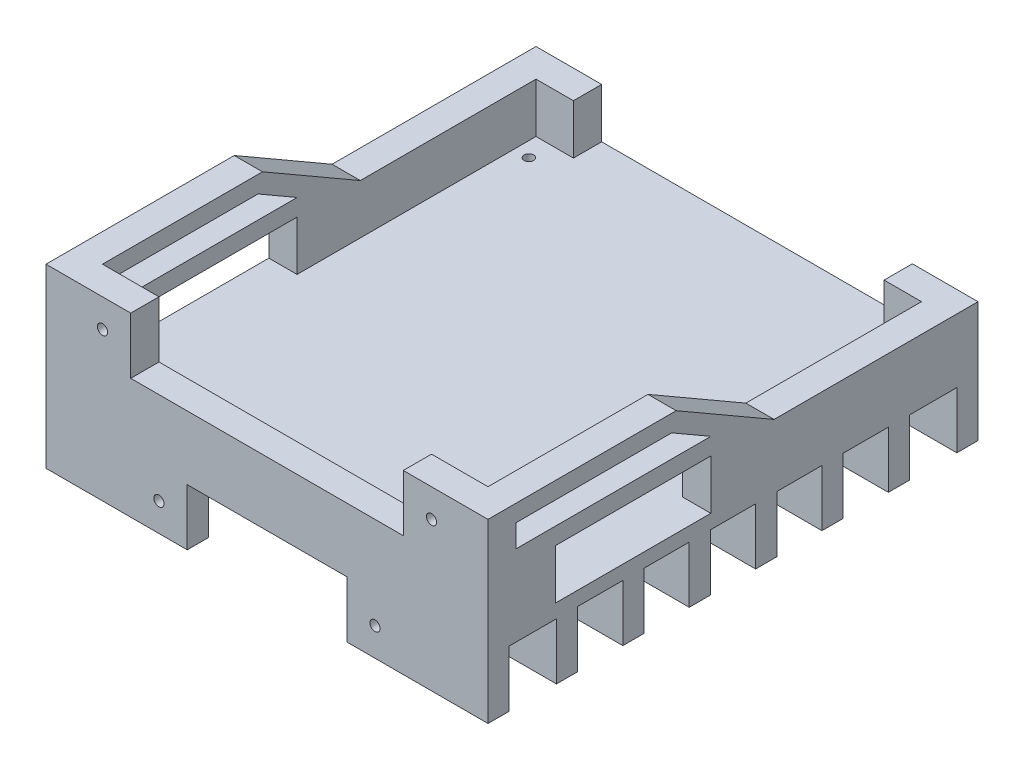
from build123d import *

# Parameters (mm, degrees)
SKETCH1_W            = 156.5
SKETCH1_H            = 173.5
BOSS_EXTRUDE1_DEPTH  = 5
BOSS_EXTRUDE2_DEPTH  = 17.6
M3_CLEARANCE_HOLE1_D = 3.4
SKETCH6_W            = 50
SKETCH6_H            = 7.5
BOSS_EXTRUDE3_DEPTH  = 20
BOSS_EXTRUDE5_DEPTH  = 10
SKETCH8_W            = 20
SKETCH8_H            = 20
SKETCH8_R            = 1.8
BOSS_EXTRUDE6_DEPTH  = 10
SKETCH9_R            = 1.8
CUT_EXTRUDE1_DEPTH   = 8.5


with BuildPart() as part:
    # Sketch1 → Boss-Extrude1 (new body)
    with BuildSketch(Plane(origin=(0, 0, 0), x_dir=(1, 0, 0), z_dir=(0, 1, 0))):
        Rectangle(SKETCH1_W, SKETCH1_H)
    extrude(amount=-BOSS_EXTRUDE1_DEPTH)

    # Sketch1_2 → Boss-Extrude2 (add)
    with BuildSketch(Plane(origin=(0, 0, 0), x_dir=(1, 0, 0), z_dir=(0, 1, 0))):
        Polygon((-78.25, -7.85), (-68.25, -7.85), (-68.25, 76.75), (-55, 76.75), (-55, 86.75), (-78.25, 86.75), align=None)
        Polygon((68.25, 76.75), (68.25, -7.85), (78.25, -7.85), (78.25, 86.75), (55, 86.75), (55, 76.75), align=None)
        Polygon((68.25, -76.75), (-68.25, -76.75), (-68.25, -62.85), (-78.25, -62.85), (-78.25, -86.75), (78.25, -86.75), (78.25, -62.85), (68.25, -62.85), align=None)
    extrude(amount=BOSS_EXTRUDE2_DEPTH)

    # M3 Clearance Hole1 (through all)
    with Locations(Plane(origin=(0, 0, 0), x_dir=(1, 0, 0), z_dir=(0, 1, 0))):
        with Locations((-63, 69), (-63, -70.35), (63, -70.35), (63, 69)):
            Hole(M3_CLEARANCE_HOLE1_D / 2)

    # Sketch6 → Boss-Extrude3 (add)
    with BuildSketch(Plane.XZ.offset(5)):
        with Locations((-53.25, 83)):
            Rectangle(SKETCH6_W, SKETCH6_H)
        with Locations((-53.25, 58.75)):
            Rectangle(SKETCH6_W, SKETCH6_H)
        with Locations((-53.25, 35.25)):
            Rectangle(SKETCH6_W, SKETCH6_H)
        with Locations((-53.25, 11.75)):
            Rectangle(SKETCH6_W, SKETCH6_H)
        with Locations((53.25, 11.75)):
            Rectangle(SKETCH6_W, SKETCH6_H)
        with Locations((53.25, 35.25)):
            Rectangle(SKETCH6_W, SKETCH6_H)
        with Locations((53.25, 58.75)):
            Rectangle(SKETCH6_W, SKETCH6_H)
        with Locations((53.25, 83)):
            Rectangle(SKETCH6_W, SKETCH6_H)
        with Locations((53.25, -83)):
            Rectangle(SKETCH6_W, SKETCH6_H)
        with Locations((53.25, -58.75)):
            Rectangle(SKETCH6_W, SKETCH6_H)
        with Locations((53.25, -35.25)):
            Rectangle(SKETCH6_W, SKETCH6_H)
        with Locations((53.25, -11.75)):
            Rectangle(SKETCH6_W, SKETCH6_H)
        with Locations((-53.25, -11.75)):
            Rectangle(SKETCH6_W, SKETCH6_H)
        with Locations((-53.25, -35.25)):
            Rectangle(SKETCH6_W, SKETCH6_H)
        with Locations((-53.25, -58.75)):
            Rectangle(SKETCH6_W, SKETCH6_H)
        with Locations((-53.25, -83)):
            Rectangle(SKETCH6_W, SKETCH6_H)
    extrude(amount=BOSS_EXTRUDE3_DEPTH)

    # Sketch7 → Boss-Extrude5 (add)
    with BuildSketch(Plane(origin=(78.25, 0, 0), x_dir=(0, 0, -1), z_dir=(1, 0, 0))):
        Polygon((-86.75, 17.6), (-86.75, 37.6), (-20.098711306, 37.6), (14.542304845, 17.6), align=None)
        Polygon((-76.75, 31.6), (-21.706406461, 31.6), (-7.85, 23.6), (-76.75, 23.6), align=None, mode=Mode.SUBTRACT)
    extrude(amount=-BOSS_EXTRUDE5_DEPTH)

    # Sketch8 → Boss-Extrude6 (add)
    with BuildSketch(Plane.XY.offset(86.75)):
        with Locations((58.25, 27.6)):
            Rectangle(SKETCH8_W, SKETCH8_H)
        with Locations((58.25, 27.6)):
            Circle(SKETCH8_R, mode=Mode.SUBTRACT)
    extrude(amount=-BOSS_EXTRUDE6_DEPTH)

    # Mirror2: part across plane


with BuildPart() as part_1:
    add(part.part)
    add(part.part.mirror(Plane(origin=(0, 0, 0), x_dir=(0, 0, 1), z_dir=(1, 0, 0))))

    # Sketch9 → Cut-Extrude1 (cut, through all)
    with BuildSketch(Plane(origin=(0, 0, 79.25), x_dir=(-1, 0, 0), z_dir=(0, 0, -1))):
        with Locations((-38.25, -15)):
            Circle(SKETCH9_R)
        with Locations((38.25, -15)):
            Circle(SKETCH9_R)
    extrude(amount=-CUT_EXTRUDE1_DEPTH, mode=Mode.SUBTRACT)


solid = part_1.part
